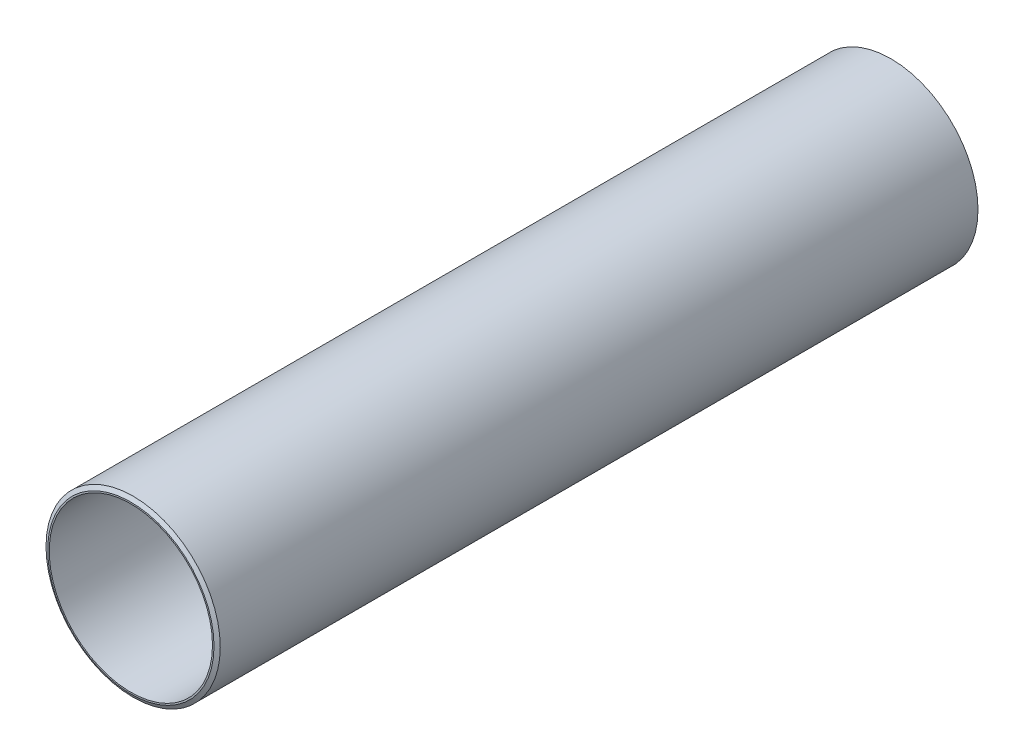
from build123d import *

# Parameters (mm, degrees)
DA_R       = 57.15
DA_R_2     = 53.55
ROHR_DEPTH = 250


with BuildPart() as part:
    # da → Rohr (new body, symmetric)
    with BuildSketch(Plane.XY):
        Circle(DA_R)
        Circle(DA_R_2, mode=Mode.SUBTRACT)
    extrude(amount=ROHR_DEPTH, both=True)

    # Skizze1 → Fase (revolve, cut)
    with BuildSketch(Plane(origin=(0, 0, 0), x_dir=(1, 0, 0), z_dir=(0, 1, 0)), mode=Mode.PRIVATE) as fase_sk:
        Polygon((-54.55, -250), (-57.15, -248.4988893), (-57.15, -250), align=None)
        Polygon((-57.15, 250), (-54.55, 250), (-57.15, 248.4988893), align=None)
    revolve(fase_sk.sketch.rotate(Axis((0, 0, 250), (0, 0, -1)), 180), axis=Axis((0, 0, 250), (0, 0, -1)), mode=Mode.SUBTRACT)  # turned: the seam where the file's is


solid = part.part
